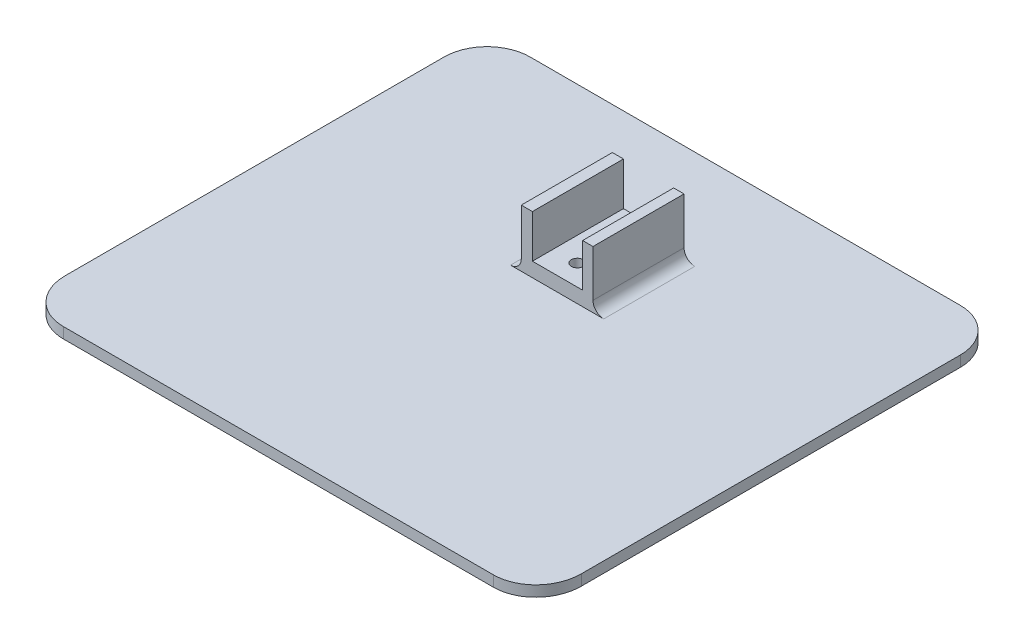
from build123d import *

# Parameters (mm, degrees)
SKETCH1_R           = 1.655864604
BOSS_EXTRUDE1_DEPTH = 3
SKETCH2_W           = 20
SKETCH2_H           = 25.399582392
SKETCH2_R           = 1.655864604
BOSS_EXTRUDE2_DEPTH = 16
SKETCH3_W           = 14
SKETCH3_H           = 30.433665038
CUT_EXTRUDE1_DEPTH  = 12
FILLET1_R           = 3
SKETCH4_R           = 3.655864604
CUT_EXTRUDE2_DEPTH  = 3


with BuildPart() as part:
    # Sketch1 → Boss-Extrude1 (new body)
    with BuildSketch(Plane(origin=(0, 0, 0), x_dir=(1, 0, 0), z_dir=(0, 1, 0))):
        with BuildLine():
            Line((-72.391156815, 44.965534322), (-72.391156815, -60.735574691))
            add(Edge.make_bspline(
                [(-72.391156815, -60.735574691), (-72.391156815, -61.992108225), (-72.131767652, -63.841263996), (-71.193134075, -66.331246924), (-70.115754462, -68.193455339), (-68.602916824, -69.990155744), (-66.871043197, -71.356237465), (-65.167773111, -72.264127558), (-63.671954883, -72.82246992), (-62.083143976, -73.170982974), (-60.950569944, -73.258988683), (-60.391156815, -73.258988683)],
                knots=[0, 0, 0, 0, 0.25, 0.375, 0.5, 0.625, 0.75, 0.8125, 0.875, 0.9375, 1, 1, 1, 1], degree=3))
            Line((-60.391156815, -73.258988683), (59.608843185, -73.258988683))
            add(Edge.make_bspline(
                [(59.608843185, -73.258988683), (60.161825687, -73.258988683), (61.27919765, -73.173963171), (62.86030745, -72.830650997), (64.348694962, -72.279953513), (66.061771772, -71.375336188), (67.804355953, -70.006238159), (69.822626853, -67.61666824), (71.258952654, -64.479060557), (71.608843185, -61.999282855), (71.608843185, -60.735574691)],
                knots=[0, 0, 0, 0, 0.0625, 0.125, 0.1875, 0.25, 0.375, 0.5, 0.75, 1, 1, 1, 1], degree=3))
            Line((71.608843185, -60.735574691), (71.608843185, 44.965534322))
            ThreePointArc((71.608843185, 44.965534322), (68.094124559, 53.450815696), (59.608843185, 56.965534322))
            Line((59.608843185, 56.965534322), (-60.391156815, 56.965534322))
            ThreePointArc((-60.391156815, 56.965534322), (-68.876438189, 53.450815696), (-72.391156815, 44.965534322))
        make_face()
        with Locations((0.208651948, 24.377980521)):
            Circle(SKETCH1_R, mode=Mode.SUBTRACT)
        with Locations((-0.01971378, 9.762573941)):
            Circle(SKETCH1_R, mode=Mode.SUBTRACT)
    extrude(amount=BOSS_EXTRUDE1_DEPTH)

    # Sketch2 → Boss-Extrude2 (add)
    with BuildSketch(Plane(origin=(0, 3, 0), x_dir=(1, 0, 0), z_dir=(0, 1, 0))):
        with Locations((0.161550821, 16.648607969)):
            Rectangle(SKETCH2_W, SKETCH2_H)
        with Locations((-0.01971378, 9.762573941)):
            Circle(SKETCH2_R, mode=Mode.SUBTRACT)
        with Locations((0.208651948, 24.377980521)):
            Circle(SKETCH2_R, mode=Mode.SUBTRACT)
    extrude(amount=BOSS_EXTRUDE2_DEPTH)

    # Sketch3 → Cut-Extrude1 (cut)
    with BuildSketch(Plane(origin=(0, 19, 0), x_dir=(1, 0, 0), z_dir=(0, 1, 0))):
        with Locations((0.269010393, 16.661700324)):
            Rectangle(SKETCH3_W, SKETCH3_H)
    extrude(amount=-CUT_EXTRUDE1_DEPTH, mode=Mode.SUBTRACT)

    # Fillet1
    fillet1_edges = [part.edges().sort_by_distance(p)[0] for p in [
        (-9.838449179, 3, -16.648607969),
        (10.161550821, 3, -16.648607969),
    ]]
    fillet(fillet1_edges, radius=FILLET1_R)

    # Sketch4 → Cut-Extrude2 (cut)
    with BuildSketch(Plane.XZ):
        with Locations((-0.01971378, -9.762573941)):
            Circle(SKETCH4_R)
        with Locations((0.208651948, -24.377980521)):
            Circle(SKETCH4_R)
    extrude(amount=-CUT_EXTRUDE2_DEPTH, mode=Mode.SUBTRACT)


solid = part.part
